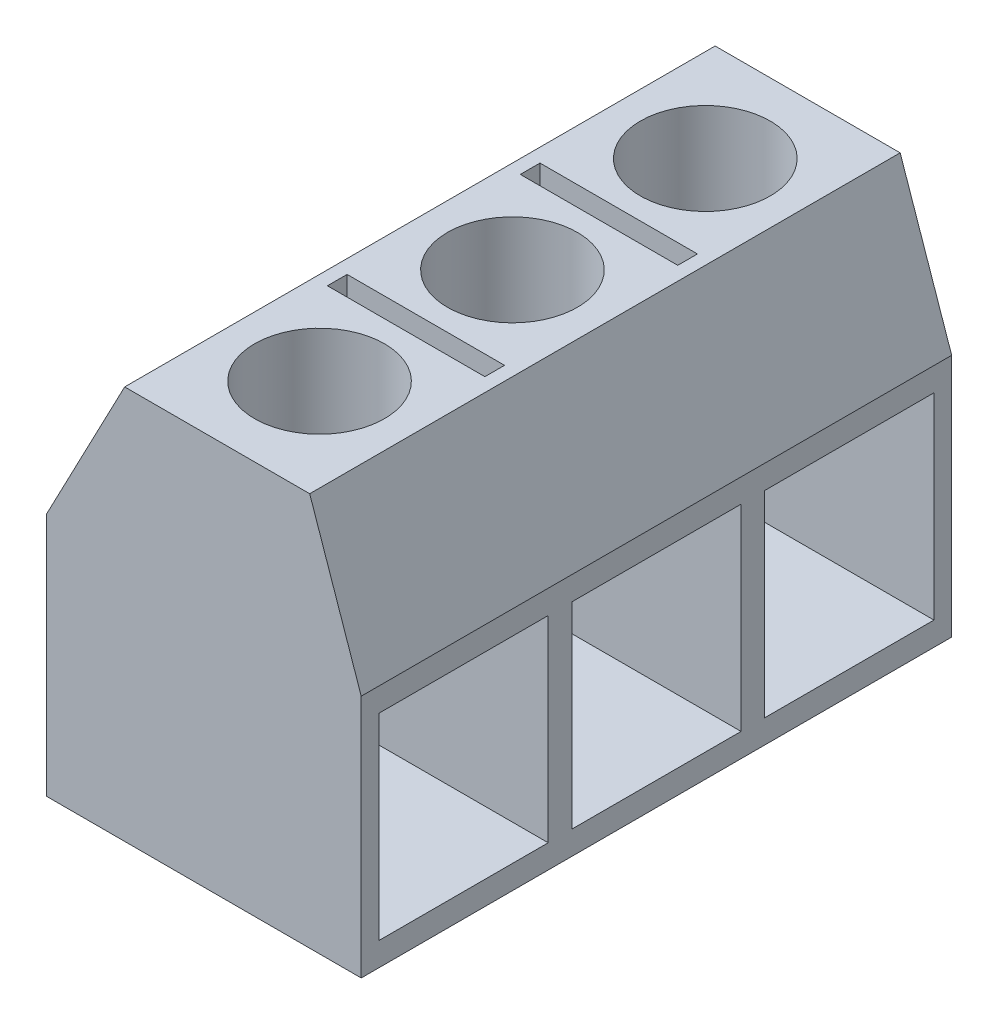
from build123d import *

# Parameters (mm, degrees)
BOSS_EXTRUDE1_DEPTH = 15
SKETCH2_R           = 1.65
SKETCH2_W           = 4
SKETCH2_H           = 0.5
CUT_EXTRUDE1_DEPTH  = 9.2
SKETCH3_W           = 4.3
SKETCH3_H           = 5
CUT_EXTRUDE2_DEPTH  = 6


with BuildPart() as part:
    # Sketch1 → Boss-Extrude1 (new body)
    with BuildSketch(Plane.XY):
        Polygon((-3.803278689, 0), (4.196721311, 0), (4.196721311, 6.2), (2.887726083, 10), (-1.812273917, 10), (-3.803278689, 6.2), align=None)
    extrude(amount=BOSS_EXTRUDE1_DEPTH)

    # Sketch2 → Cut-Extrude1 (cut)
    with BuildSketch(Plane(origin=(0, 10, 0), x_dir=(1, 0, 0), z_dir=(0, 1, 0))):
        with Locations((0.537726083, -12.4)):
            Circle(SKETCH2_R)
        with Locations((0.537726083, -7.5)):
            Circle(SKETCH2_R)
        with Locations((0.537726083, -2.6)):
            Circle(SKETCH2_R)
        with Locations((0.537726083, -9.95)):
            Rectangle(SKETCH2_W, SKETCH2_H)
        with Locations((0.537726083, -5.05)):
            Rectangle(SKETCH2_W, SKETCH2_H)
    extrude(amount=-CUT_EXTRUDE1_DEPTH, mode=Mode.SUBTRACT)

    # Sketch3 → Cut-Extrude2 (cut)
    with BuildSketch(Plane(origin=(4.196721311, 0, 0), x_dir=(0, 0, -1), z_dir=(1, 0, 0))):
        with Locations((-12.4, 3.1)):
            Rectangle(SKETCH3_W, SKETCH3_H)
        with Locations((-7.5, 3.1)):
            Rectangle(SKETCH3_W, SKETCH3_H)
        with Locations((-2.6, 3.1)):
            Rectangle(SKETCH3_W, SKETCH3_H)
    extrude(amount=-CUT_EXTRUDE2_DEPTH, mode=Mode.SUBTRACT)


solid = part.part
